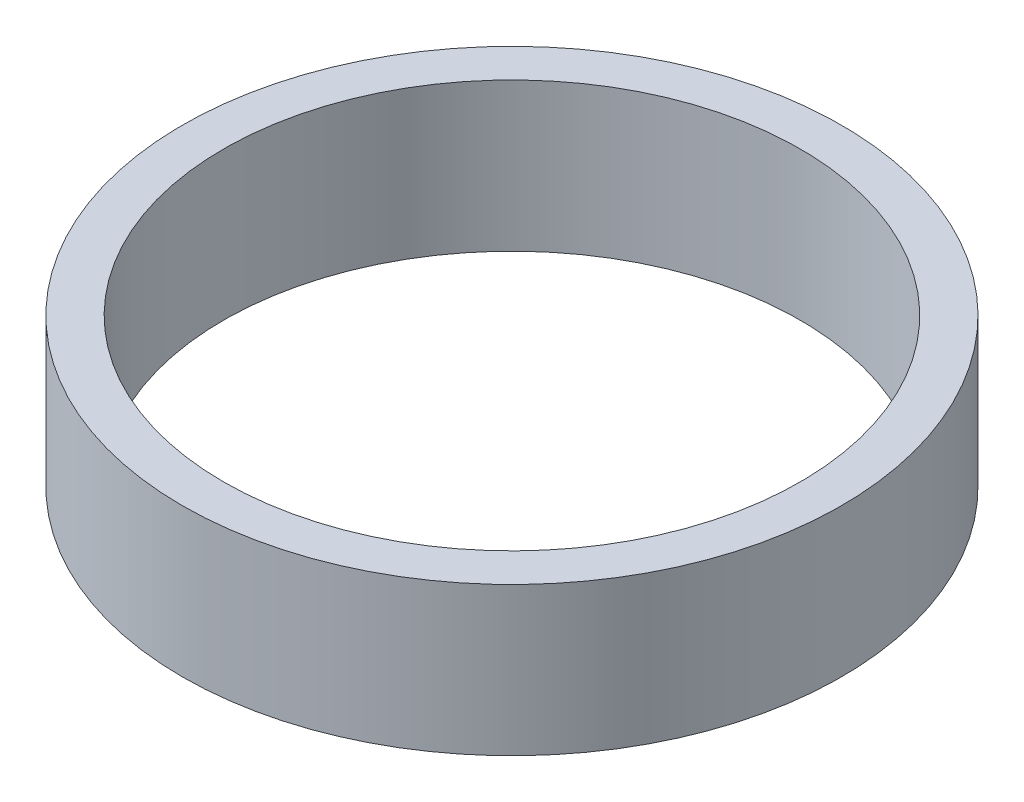
from build123d import *

# Parameters (mm, degrees)
SKETCH1_R           = 20
SKETCH1_R_2         = 17.5
BOSS_EXTRUDE1_DEPTH = 9


with BuildPart() as part:
    # Sketch1 → Boss-Extrude1 (new body)
    with BuildSketch(Plane(origin=(0, 0, 0), x_dir=(1, 0, 0), z_dir=(0, 1, 0))):
        Circle(SKETCH1_R)
        Circle(SKETCH1_R_2, mode=Mode.SUBTRACT)
    extrude(amount=BOSS_EXTRUDE1_DEPTH)


solid = part.part
